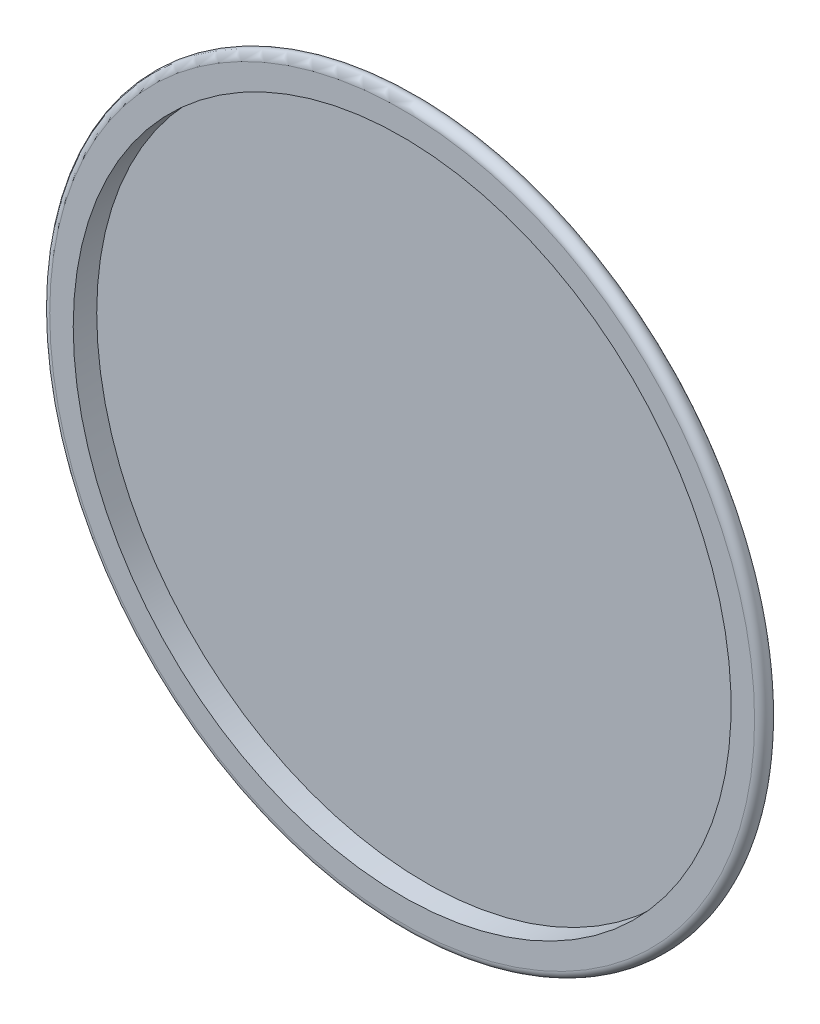
from build123d import *


with BuildPart() as part:
    # Croquis1 → Revolución1 (revolve)
    with BuildSketch(Plane(origin=(0, 0, 0), x_dir=(1, 0, 0), z_dir=(0, 1, 0))):
        with BuildLine():
            Line((21, 0), (22.5, 0))
            ThreePointArc((22.5, 0), (22.971057488, 0.33235501), (22.815881711, 0.88758063))
            ThreePointArc((22.815881711, 0.88758063), (21.494164727, 1.662049929), (20, 2))
            Line((20, 2), (0, 2))
            Line((0, 2), (0, 1.5))
            Line((0, 1.5), (21, 1.5))
            Line((21, 1.5), (21, 0))
        make_face()
    revolve(axis=Axis((0, 0, -2), (0, 0, 1)))


solid = part.part
